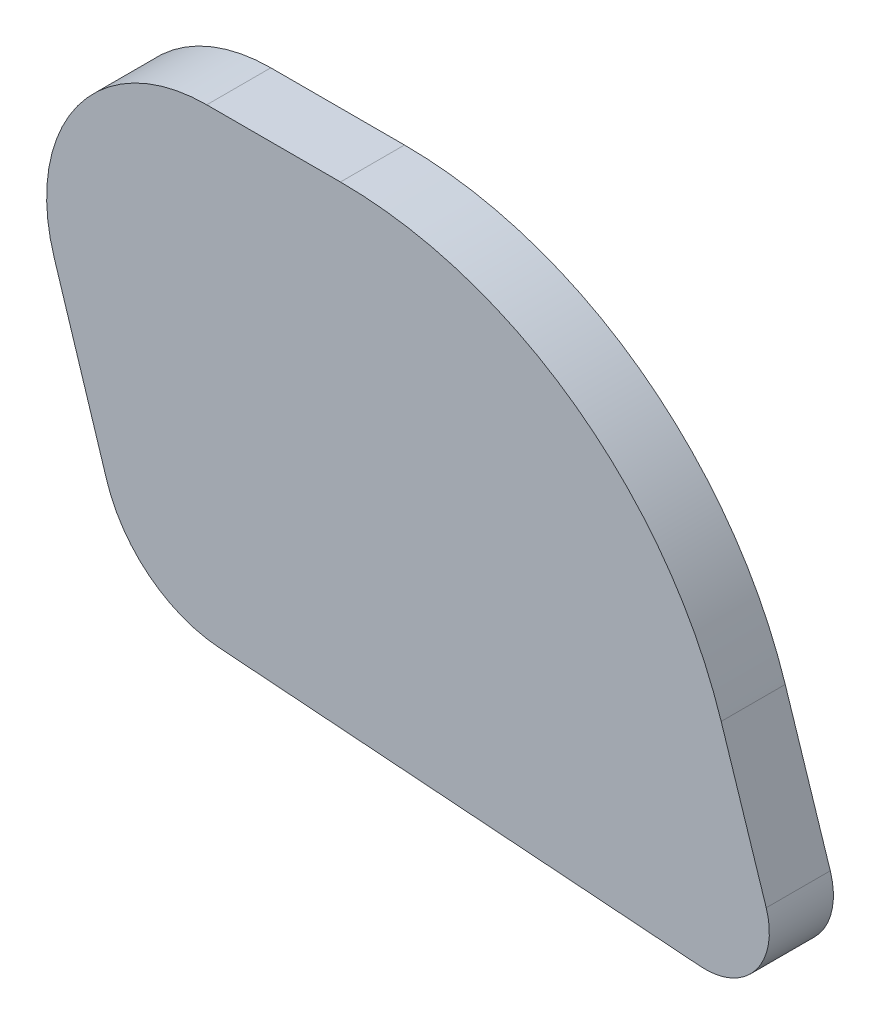
from build123d import *

# Parameters (mm, degrees)
BOSS_EXTRUDE1_DEPTH = 4
SCALE1_SCALE        = 0.709677419


with BuildPart() as part:
    # Sketch1 → Boss-Extrude1 (new body)
    with BuildSketch(Plane.XY):
        with BuildLine():
            Line((150.379434294, 210.939689278), (158.72889788, 210.939689278))
            ThreePointArc((158.72889788, 210.939689278), (173.428975494, 206.161156043), (182.509468353, 193.652306729))
            Line((182.509468353, 193.652306729), (185.322557622, 184.978614816))
            ThreePointArc((185.322557622, 184.978614816), (184.66479187, 181.275668941), (181.2248759, 179.755326197))
            Line((181.2248759, 179.755326197), (151.16831456, 181.96131235))
            ThreePointArc((151.16831456, 181.96131235), (146.791215107, 183.665156491), (144.12485117, 187.532014108))
            Line((144.12485117, 187.532014108), (140.843128941, 197.929891907))
            ThreePointArc((140.843128941, 197.929891907), (142.314139082, 206.851627467), (150.379434294, 210.939689278))
        make_face()
    extrude(amount=BOSS_EXTRUDE1_DEPTH)


with BuildPart() as part_1:
    # Scale1: scaled about (162.020760572, 194.926645474, 2)
    add(part.part.scale(SCALE1_SCALE).moved(Location((47.038285327, 56.591606751, 0.580645161))))


solid = part_1.part
